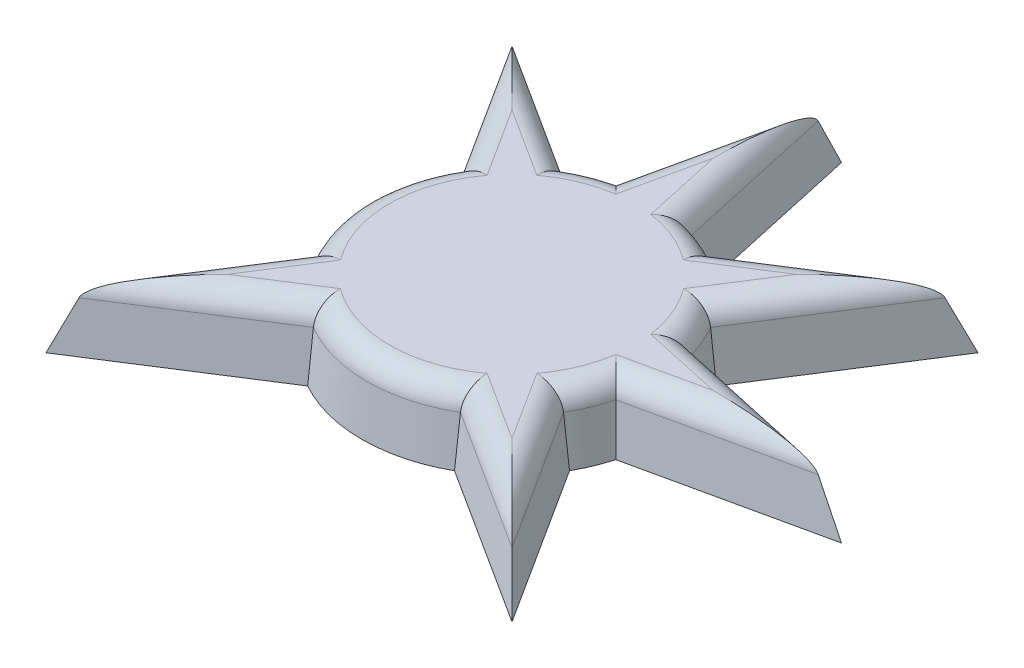
from build123d import *

# Parameters (mm, degrees)
BOSS_EXTRUDE1_DEPTH = 3
BOSS_EXTRUDE1_TAPER = 6
FILLET1_R           = 1


with BuildPart() as part:
    # Sketch2 → Boss-Extrude1 (new body)
    with BuildSketch(Plane(origin=(0, 0, 0), x_dir=(1, 0, 0), z_dir=(0, 1, 0))):
        with BuildLine():
            Line((1.794958228, 6.376825284), (0, 14.54359673))
            Line((0, 14.54359673), (-1.794958228, 6.376825284))
            ThreePointArc((-1.794958228, 6.376825284), (-2.535137681, 6.120363771), (-3.239869266, 5.778323536))
            Line((-3.239869266, 5.778323536), (-10.283875871, 10.283875871))
            Line((-10.283875871, 10.283875871), (-5.778323536, 3.239869266))
            ThreePointArc((-5.778323536, 3.239869266), (-6.624634009, 0), (-5.778323536, -3.239869266))
            Line((-5.778323536, -3.239869266), (-10.283875871, -10.283875871))
            Line((-10.283875871, -10.283875871), (-3.239869266, -5.778323536))
            ThreePointArc((-3.239869266, -5.778323536), (0, -6.624634009), (3.239869266, -5.778323536))
            Line((3.239869266, -5.778323536), (10.283875871, -10.283875871))
            Line((10.283875871, -10.283875871), (5.778323536, -3.239869266))
            ThreePointArc((5.778323536, -3.239869266), (6.120363771, -2.535137681), (6.376825284, -1.794958228))
            Line((6.376825284, -1.794958228), (14.54359673, 0))
            Line((14.54359673, 0), (6.376825284, 1.794958228))
            ThreePointArc((6.376825284, 1.794958228), (6.120363771, 2.535137681), (5.778323536, 3.239869266))
            Line((5.778323536, 3.239869266), (10.283875871, 10.283875871))
            Line((10.283875871, 10.283875871), (3.239869266, 5.778323536))
            ThreePointArc((3.239869266, 5.778323536), (2.535137681, 6.120363771), (1.794958228, 6.376825284))
        make_face()
    extrude(amount=BOSS_EXTRUDE1_DEPTH, taper=BOSS_EXTRUDE1_TAPER)

    # Fillet1
    fillet1_edges = [part.edges().sort_by_distance(p)[0] for p in [
        (-6.309321303, 3, 0),
        (-7.327188827, 3, -6.246552279),
        (-6.246552279, 3, -7.327188827),
        (-2.414472732, 3, -5.829052816),
        (-0.764125431, 3, -9.598084382),
        (0.764125431, 3, -9.598084382),
        (2.414472732, 3, -5.829052816),
        (6.246552279, 3, -7.327188827),
        (7.327188827, 3, -6.246552279),
        (5.829052816, 3, -2.414472732),
        (9.598084382, 3, -0.764125431),
        (9.598084382, 3, 0.764125431),
        (5.829052816, 3, 2.414472732),
        (7.327188827, 3, 6.246552279),
        (6.246552279, 3, 7.327188827),
        (0, 3, 6.309321303),
        (-6.246552279, 3, 7.327188827),
        (-7.327188827, 3, 6.246552279),
    ]]
    fillet(fillet1_edges, radius=FILLET1_R)


solid = part.part
